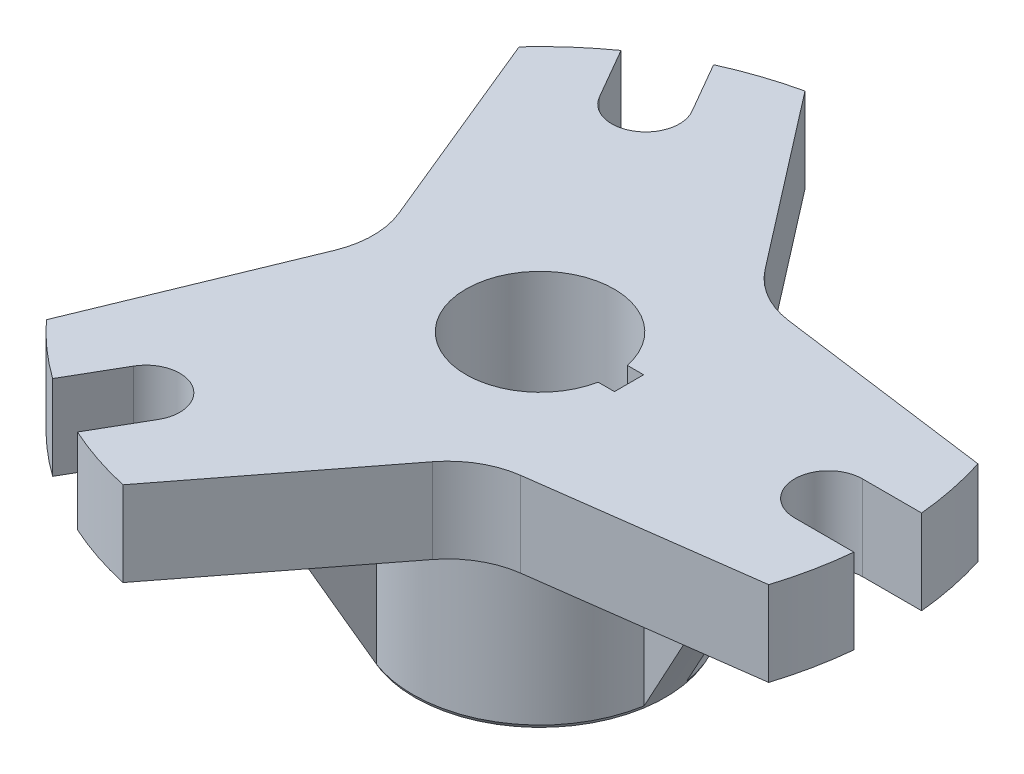
from build123d import *

# Parameters (mm, degrees)
SKETCH1_R                = 82.5
BOSS_EXTRUDE1_DEPTH      = 20
SKETCH2_R                = 30
BOSS_EXTRUDE2_DEPTH      = 40
SKETCH3_R                = 17.5
CUT_EXTRUDE1_DEPTH       = 61
BOSS_EXTRUDE3_DEPTH      = 5
CIRPATTERN4_COUNT        = 3
CUT_EXTRUDE13_DEPTH      = 21
CIRPATTERN5_COUNT        = 3
CUT_EXTRUDE14_DEPTH      = 21
CIRPATTERN6_COUNT        = 3
CUT_EXTRUDE15_DEPTH      = 21
CUT_EXTRUDE15_DEPTH_BACK = 41


with BuildPart() as part:
    # Sketch1 → Boss-Extrude1 (new body)
    with BuildSketch(Plane(origin=(0, 0, 0), x_dir=(1, 0, 0), z_dir=(0, 1, 0))):
        Circle(SKETCH1_R)
    extrude(amount=BOSS_EXTRUDE1_DEPTH)

    # Sketch2 → Boss-Extrude2 (add)
    with BuildSketch(Plane.XZ):
        Circle(SKETCH2_R)
    extrude(amount=BOSS_EXTRUDE2_DEPTH)

    # Sketch3 → Cut-Extrude1 (cut, through all)
    with BuildSketch(Plane.XZ.offset(40)):
        Circle(SKETCH3_R)
    extrude(amount=-CUT_EXTRUDE1_DEPTH, mode=Mode.SUBTRACT)

    # Sketch4 → Boss-Extrude3 (add, symmetric)
    with BuildSketch(Plane.XY):
        Polygon((26.043936365, 0), (51.043936365, 0), (30, -40), (26.043936365, -40), align=None)
    boss_extrude3 = extrude(amount=BOSS_EXTRUDE3_DEPTH, both=True)

    # CirPattern4: Boss-Extrude3 ×3 about axis
    cirpattern4_axis = Axis((0, 0, 0), (0, 1, 0))
    for i in range(1, CIRPATTERN4_COUNT):
        add(boss_extrude3.rotate(cirpattern4_axis, i * 360 / CIRPATTERN4_COUNT))

    # Sketch5 → Cut-Revolve1 (revolve, cut)
    with BuildSketch(Plane.XY):
        Polygon((51.043936365, 0), (29.580398915, -40), (54.67204938, -40), align=None)
    revolve(axis=Axis((0, 0, 0), (0, -1, 0)), mode=Mode.SUBTRACT)

    # Sketch10 → Cut-Extrude13 (cut, through all)
    with BuildSketch(Plane(origin=(0, 0, 0), x_dir=(1, 0, 0), z_dir=(0, 1, 0))):
        with BuildLine():
            ThreePointArc((-60.756737715, -55.811009866), (-82.5, 0), (-60.756737715, 55.811009866))
            Line((-60.756737715, 55.811009866), (-40.932429831, 7.606987591))
            ThreePointArc((-40.932429831, 7.606987591), (-39.429287397, 0), (-40.932429831, -7.606987591))
            Line((-40.932429831, -7.606987591), (-60.756737715, -55.811009866))
        make_face()
    cut_extrude13 = extrude(amount=CUT_EXTRUDE13_DEPTH, mode=Mode.SUBTRACT)

    # CirPattern5: Cut-Extrude13 ×3 about axis
    cirpattern5_axis = Axis((0, 0, 0), (0, 1, 0))
    for i in range(1, CIRPATTERN5_COUNT):
        add(cut_extrude13.rotate(cirpattern5_axis, i * 360 / CIRPATTERN5_COUNT), mode=Mode.SUBTRACT)

    # Sketch11 → Cut-Extrude14 (cut, through all)
    with BuildSketch(Plane(origin=(0, 0, 0), x_dir=(1, 0, 0), z_dir=(0, 1, 0))):
        with BuildLine():
            Line((68.125333986, 8), (82.111205082, 8))
            ThreePointArc((82.111205082, 8), (82.5, 0), (82.111205082, -8))
            Line((82.111205082, -8), (68.125333986, -8))
            ThreePointArc((68.125333986, -8), (60.125333986, 0), (68.125333986, 8))
        make_face()
    cut_extrude14 = extrude(amount=CUT_EXTRUDE14_DEPTH, mode=Mode.SUBTRACT)

    # CirPattern6: Cut-Extrude14 ×3 about axis
    cirpattern6_axis = Axis((0, 0, 0), (0, 1, 0))
    for i in range(1, CIRPATTERN6_COUNT):
        add(cut_extrude14.rotate(cirpattern6_axis, i * 360 / CIRPATTERN6_COUNT), mode=Mode.SUBTRACT)

    # Sketch13 → Cut-Extrude15 (cut, two sides)
    with BuildSketch(Plane(origin=(0, 0, 0), x_dir=(1, 0, 0), z_dir=(0, 1, 0))) as cut_extrude15_sk:
        with BuildLine():
            Line((17.15731582, 3.446231834), (21.015929185, 3.446231834))
            Line((21.015929185, 3.446231834), (21.015929185, -3.446231834))
            Line((21.015929185, -3.446231834), (17.15731582, -3.446231834))
            ThreePointArc((17.15731582, -3.446231834), (17.5, 0), (17.15731582, 3.446231834))
        make_face()
    extrude(amount=CUT_EXTRUDE15_DEPTH, mode=Mode.SUBTRACT)
    extrude(cut_extrude15_sk.sketch, amount=-CUT_EXTRUDE15_DEPTH_BACK, mode=Mode.SUBTRACT)


solid = part.part
